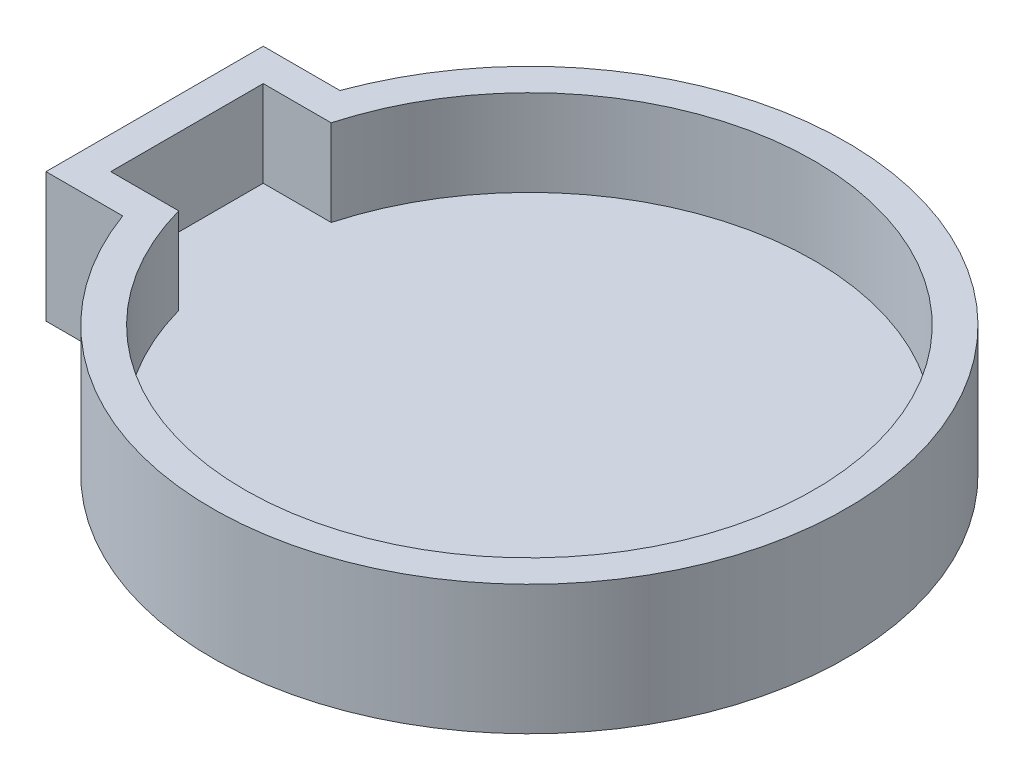
from build123d import *

# Parameters (mm, degrees)
EXTRUDE_1_DEPTH = 3
EXTRUDE_2_DEPTH = 6


with BuildPart() as part:
    # 스케치1 → 보스-돌출1 (new body)
    with BuildSketch(Plane(origin=(0, 0, 0), x_dir=(1, 0, 0), z_dir=(0, 1, 0))):
        with BuildLine():
            Line((-26.05, 7.55), (-20.71714266, 7.55))
            ThreePointArc((-20.71714266, 7.55), (22.05, 0), (-20.71714266, -7.55))
            Line((-20.71714266, -7.55), (-26.05, -7.55))
            Line((-26.05, -7.55), (-26.05, 7.55))
        make_face()
    extrude(amount=EXTRUDE_1_DEPTH)

    # 스케치2 → 보스-돌출2 (add)
    with BuildSketch(Plane(origin=(0, 3, 0), x_dir=(1, 0, 0), z_dir=(0, 1, 0))):
        with BuildLine():
            Line((-26.05, 7.55), (-26.05, -7.55))
            Line((-26.05, -7.55), (-20.71714266, -7.55))
            ThreePointArc((-20.71714266, -7.55), (22.05, 0), (-20.71714266, 7.55))
            Line((-20.71714266, 7.55), (-26.05, 7.55))
        make_face()
        with BuildLine():
            Line((-19.077473627, 5.3), (-23.8, 5.3))
            Line((-23.8, 5.3), (-23.8, -5.3))
            Line((-23.8, -5.3), (-19.077473627, -5.3))
            ThreePointArc((-19.077473627, -5.3), (19.8, 0), (-19.077473627, 5.3))
        make_face(mode=Mode.SUBTRACT)
    extrude(amount=EXTRUDE_2_DEPTH)


solid = part.part
